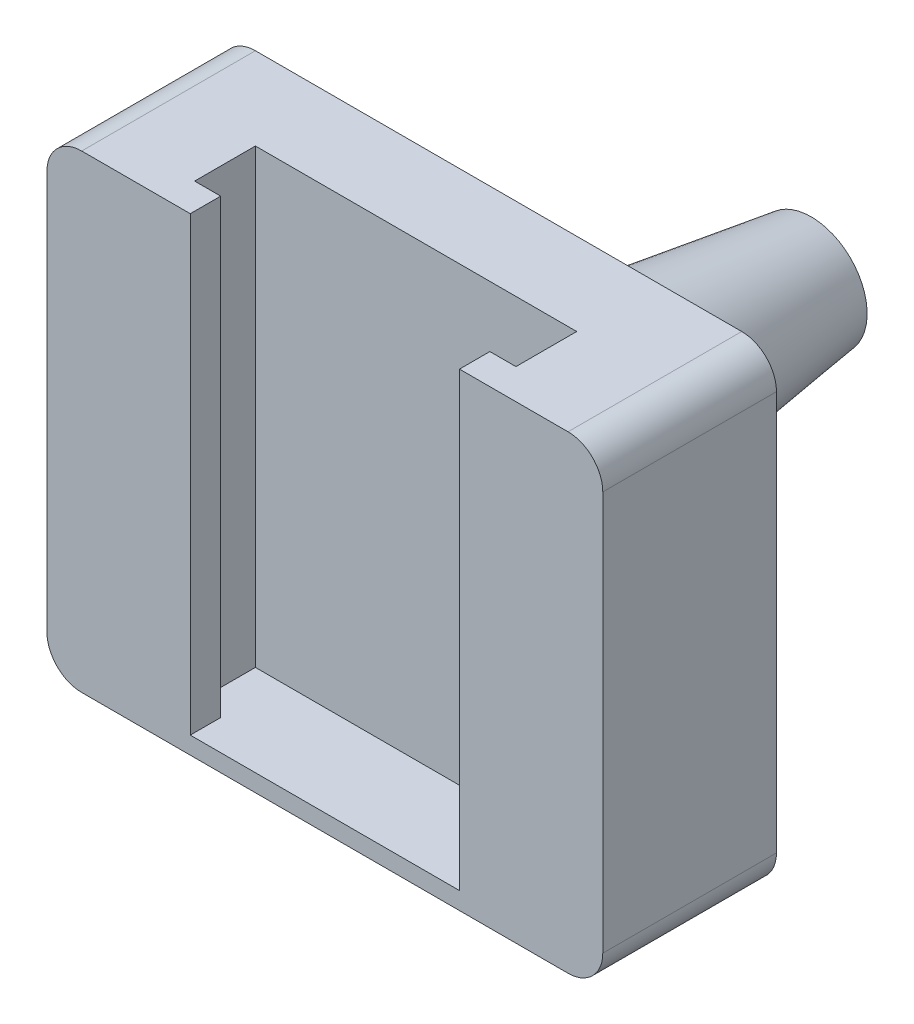
from build123d import *

# Parameters (mm, degrees)
SKETCH1_W           = 32
SKETCH1_H           = 27
BOSS_EXTRUDE1_DEPTH = 10
FILLET1_R           = 2
CUT_EXTRUDE4_DEPTH  = 26
SKETCH4_R           = 5.75
BOSS_EXTRUDE2_DEPTH = 18
BOSS_EXTRUDE2_TAPER = 8
FILLET2_R           = 2


with BuildPart() as part:
    # Sketch1 → Boss-Extrude1 (new body)
    with BuildSketch(Plane.XY):
        Rectangle(SKETCH1_W, SKETCH1_H)
    extrude(amount=BOSS_EXTRUDE1_DEPTH)

    # Fillet1
    fillet1_edges = [part.edges().sort_by_distance(p)[0] for p in [
        (-16, -13.5, 5),
        (16, -13.5, 5),
        (16, 13.5, 5),
        (-16, 13.5, 5),
    ]]
    fillet(fillet1_edges, radius=FILLET1_R)

    # Sketch2 → Cut-Extrude4 (cut)
    with BuildSketch(Plane(origin=(0, 13.5, 0), x_dir=(1, 0, 0), z_dir=(0, 1, 0))):
        Polygon((-7.75, -10), (-7.75, -8.25), (-9.25, -8.25), (-9.25, -4.75), (9.25, -4.75), (9.25, -8.25), (7.75, -8.25), (7.75, -10), align=None)
    extrude(amount=-CUT_EXTRUDE4_DEPTH, mode=Mode.SUBTRACT)

    # Sketch4 → Boss-Extrude2 (add)
    with BuildSketch(Plane(origin=(0, 0, 0), x_dir=(-1, 0, 0), z_dir=(0, 0, -1))):
        Circle(SKETCH4_R)
    extrude(amount=BOSS_EXTRUDE2_DEPTH, taper=BOSS_EXTRUDE2_TAPER)

    # Fillet2
    fillet2_edges = [part.edges().sort_by_distance(p)[0] for p in [
        (5.75, 0, 0),
    ]]
    fillet(fillet2_edges, radius=FILLET2_R)


solid = part.part
